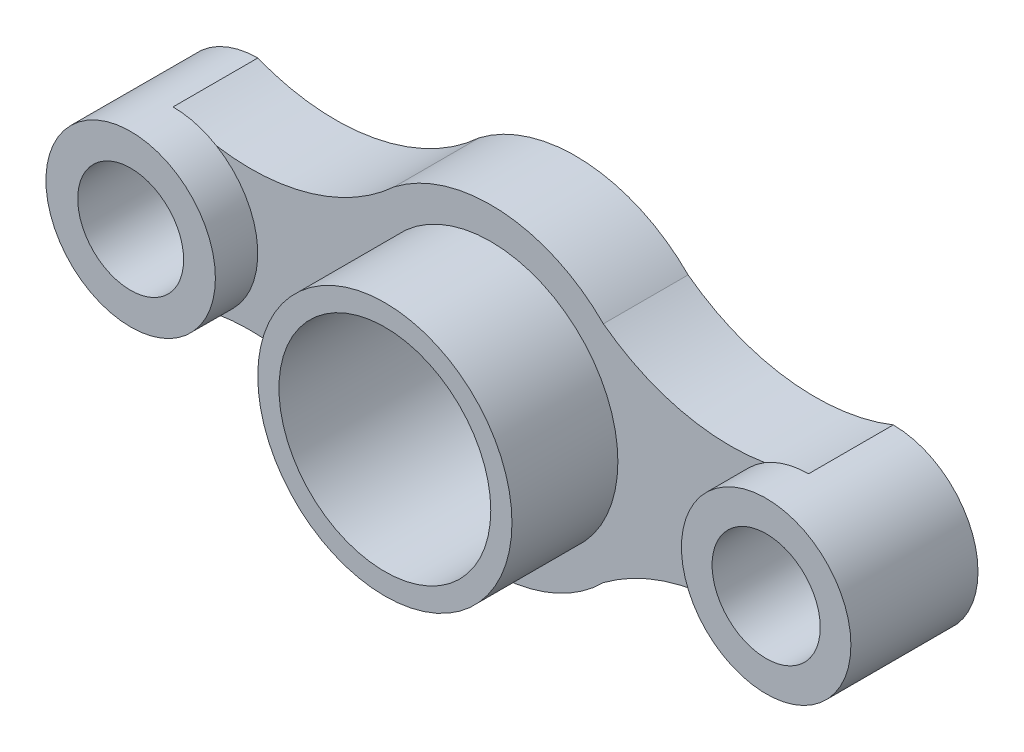
from build123d import *

# Parameters (mm, degrees)
SKETCH1_R           = 25
SKETCH1_R_2         = 25.531825786
BOSS_EXTRUDE1_DEPTH = 40
SKETCH2_R           = 40
SKETCH2_R_2         = 25
SKETCH2_R_3         = 25.531825786
BOSS_EXTRUDE2_DEPTH = 20
SKETCH3_R           = 60
SKETCH3_R_2         = 50
BOSS_EXTRUDE3_DEPTH = 50
SKETCH4_R           = 50
CUT_EXTRUDE1_DEPTH  = 50


with BuildPart() as part:
    # Sketch1 → Boss-Extrude1 (new body)
    with BuildSketch(Plane.XY):
        with BuildLine():
            ThreePointArc((-150, -40), (-94.903714286, -34.773015604), (-45.465365878, -59.648139163))
            ThreePointArc((-45.465365878, -59.648139163), (5.116377771, -74.825281012), (53.161436396, -52.904269017))
            ThreePointArc((53.161436396, -52.904269017), (99.897642557, -33.821692035), (150, -40))
            ThreePointArc((150, -40), (190, 0), (150, 40))
            ThreePointArc((150, 40), (99.897642557, 33.821692035), (53.161436396, 52.904269017))
            ThreePointArc((53.161436396, 52.904269017), (5.116377771, 74.825281012), (-45.465365878, 59.648139163))
            ThreePointArc((-45.465365878, 59.648139163), (-94.903714286, 34.773015604), (-150, 40))
            ThreePointArc((-150, 40), (-190, 0), (-150, -40))
        make_face()
        with Locations((-150, 0)):
            Circle(SKETCH1_R, mode=Mode.SUBTRACT)
        with Locations((150, 0)):
            Circle(SKETCH1_R_2, mode=Mode.SUBTRACT)
    extrude(amount=BOSS_EXTRUDE1_DEPTH)

    # Sketch2 → Boss-Extrude2 (add)
    with BuildSketch(Plane.XY.offset(40)):
        with Locations((-150, 0)):
            Circle(SKETCH2_R)
        with Locations((-150, 0)):
            Circle(SKETCH2_R_2, mode=Mode.SUBTRACT)
        with Locations((150, 0)):
            Circle(SKETCH2_R)
        with Locations((150, 0)):
            Circle(SKETCH2_R_3, mode=Mode.SUBTRACT)
    extrude(amount=BOSS_EXTRUDE2_DEPTH)

    # Sketch3 → Boss-Extrude3 (add)
    with BuildSketch(Plane.XY.offset(40)):
        Circle(SKETCH3_R)
        Circle(SKETCH3_R_2, mode=Mode.SUBTRACT)
    extrude(amount=BOSS_EXTRUDE3_DEPTH)

    # Sketch4 → Cut-Extrude1 (cut)
    with BuildSketch(Plane.XY.offset(40)):
        Circle(SKETCH4_R)
    extrude(amount=-CUT_EXTRUDE1_DEPTH, mode=Mode.SUBTRACT)


solid = part.part
